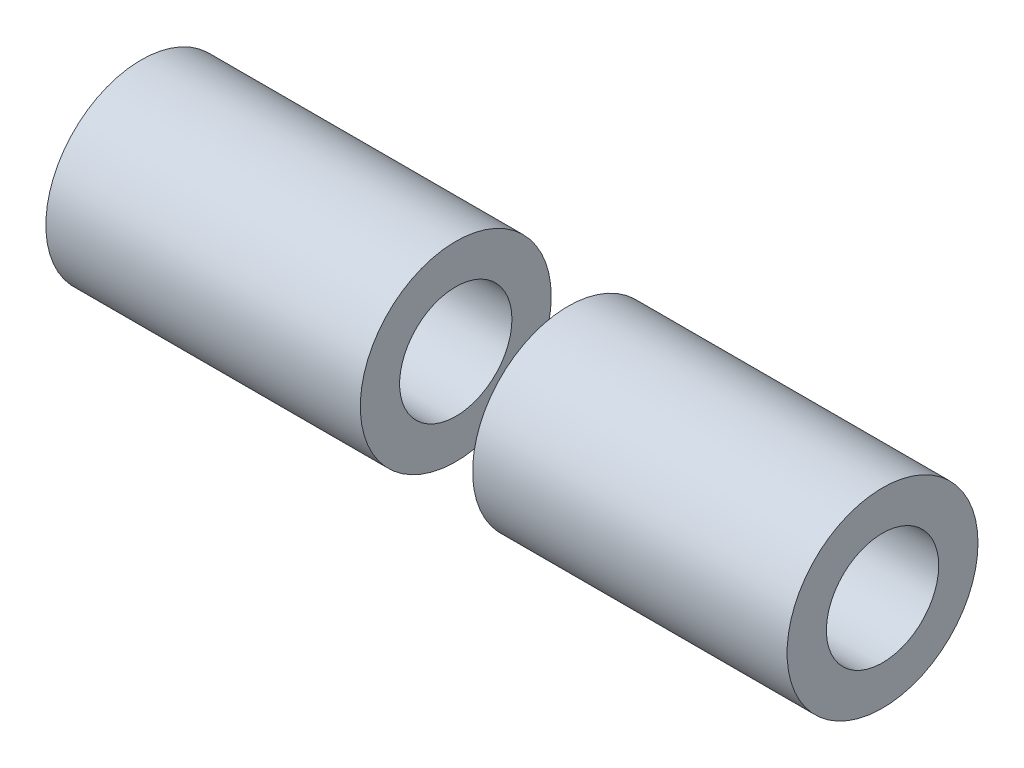
from build123d import *

# Parameters (mm, degrees)
BOSS_EXTRUDE1_START = 5
SKETCH1_R           = 8.5
SKETCH1_R_2         = 5
BOSS_EXTRUDE1_DEPTH = 28


with BuildPart() as part:
    # Sketch1 → Boss-Extrude1 (new body)
    with BuildSketch(Plane(origin=(0, 0, 0), x_dir=(0, 0, -1), z_dir=(1, 0, 0)).offset(BOSS_EXTRUDE1_START)):
        Circle(SKETCH1_R)
        Circle(SKETCH1_R_2, mode=Mode.SUBTRACT)
    extrude(amount=BOSS_EXTRUDE1_DEPTH)


with BuildPart() as body_2:
    # Mirror2: mirrored copy
    add(part.part.mirror(Plane(origin=(0, 0, 0), x_dir=(0, 0, 1), z_dir=(1, 0, 0))))


solid = Compound([part.part, body_2.part])
